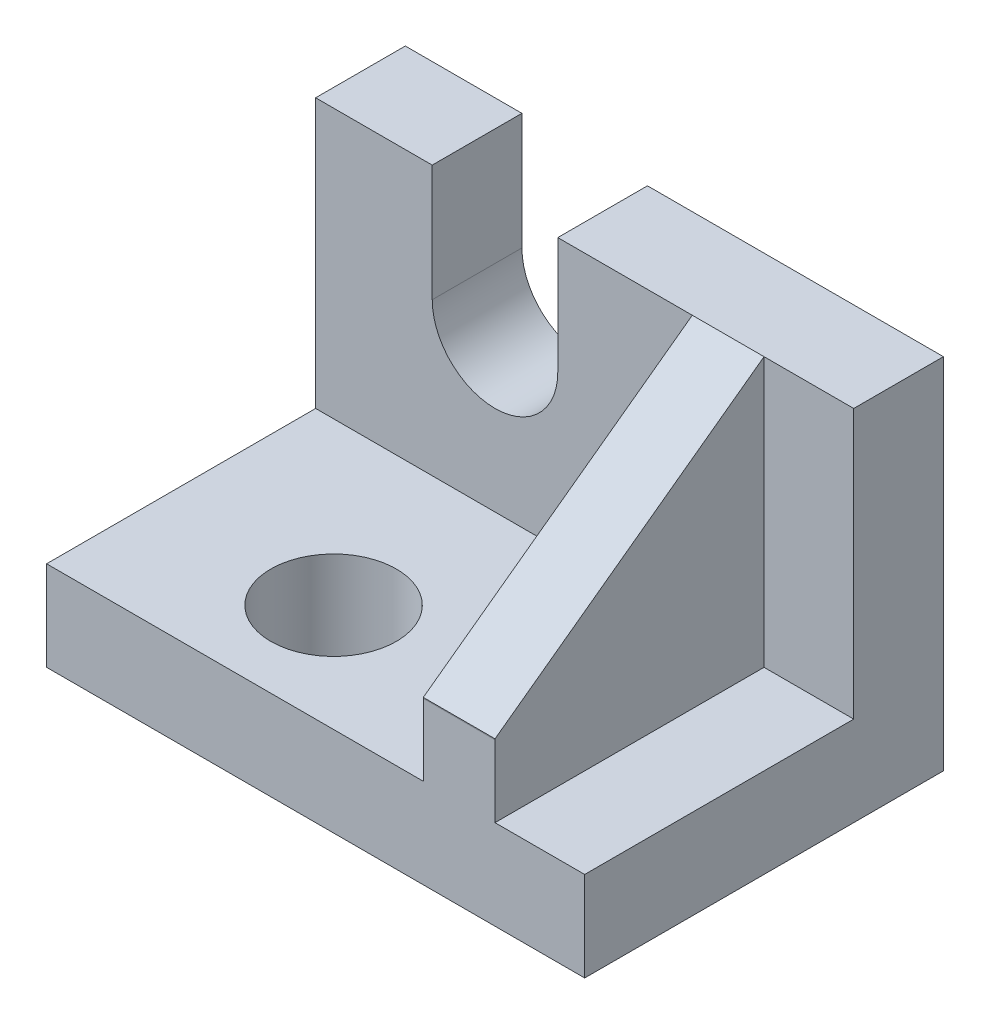
from build123d import *

# Parameters (mm, degrees)
SKETCH_3_W               = 60
SKETCH_3_H               = 40
EXTRUDE_2_DEPTH          = 40
CUT_EXTRUDE_1_DEPTH      = 39
CUT_EXTRUDE_1_DEPTH_BACK = 0.0001
SKETCH_5_W               = 10
SKETCH_5_H               = 30
CUT_EXTRUDE_2_DEPTH      = 43
SKETCH_6_W               = 14
SKETCH_6_H               = 13
CUT_EXTRUDE_3_DEPTH      = 34
SKETCH_7_W               = 14
SKETCH_7_H               = 13
CUT_EXTRUDE_4_DEPTH      = 34
CUT_EXTRUDE_5_DEPTH      = 34
CUT_EXTRUDE_7_DEPTH      = 34
SKETCH_11_R              = 7
CUT_EXTRUDE_8_DEPTH      = 37


with BuildPart() as part:
    # 草图3 → 凸台-拉伸2 (new body)
    with BuildSketch(Plane(origin=(0, 0, 0), x_dir=(1, 0, 0), z_dir=(0, 1, 0))):
        with Locations((-30, -20)):
            Rectangle(SKETCH_3_W, SKETCH_3_H)
    extrude(amount=EXTRUDE_2_DEPTH)

    # 草图4 → 切除-拉伸1 (cut, two sides)
    with BuildSketch(Plane.XY.offset(10)) as cut_extrude_1_sk:
        Polygon((-60, 40), (-47, 40), (-47, 27), (-33, 27), (-33, 40), (-18, 40), (-18, 10), (-60, 10), align=None)
    extrude(amount=CUT_EXTRUDE_1_DEPTH, mode=Mode.SUBTRACT)
    extrude(cut_extrude_1_sk.sketch, amount=-CUT_EXTRUDE_1_DEPTH_BACK, mode=Mode.SUBTRACT)

    # 草图5 → 切除-拉伸2 (cut)
    with BuildSketch(Plane.XY.offset(10)):
        with Locations((-5, 25)):
            Rectangle(SKETCH_5_W, SKETCH_5_H)
    extrude(amount=CUT_EXTRUDE_2_DEPTH, mode=Mode.SUBTRACT)

    # 草图6 → 切除-拉伸3 (cut)
    with BuildSketch(Plane.XY.offset(10)):
        with Locations((-40, 33.5)):
            Rectangle(SKETCH_6_W, SKETCH_6_H)
    extrude(amount=CUT_EXTRUDE_3_DEPTH, mode=Mode.SUBTRACT)

    # 草图7 → 切除-拉伸4 (cut)
    with BuildSketch(Plane.XY.offset(10)):
        with Locations((-40, 33.5)):
            Rectangle(SKETCH_7_W, SKETCH_7_H)
    extrude(amount=-CUT_EXTRUDE_4_DEPTH, mode=Mode.SUBTRACT)

    # 草图8 → 切除-拉伸5 (cut)
    with BuildSketch(Plane.XY.offset(10)):
        with BuildLine():
            Line((-47, 27), (-33, 27))
            ThreePointArc((-33, 27), (-40, 20), (-47, 27))
        make_face()
    extrude(amount=-CUT_EXTRUDE_5_DEPTH, mode=Mode.SUBTRACT)

    # 草图10 → 切除-拉伸7 (cut)
    with BuildSketch(Plane(origin=(0, 0, 0), x_dir=(0, 0, -1), z_dir=(1, 0, 0))):
        Polygon((-40, 40), (-40, 18), (-39.997988347, 18.098350801), (-10, 40), align=None)
    extrude(amount=-CUT_EXTRUDE_7_DEPTH, mode=Mode.SUBTRACT)

    # 草图11 → 切除-拉伸8 (cut)
    with BuildSketch(Plane(origin=(0, 0, 0), x_dir=(1, 0, 0), z_dir=(0, 1, 0))):
        with Locations((-40, -28)):
            Circle(SKETCH_11_R)
    extrude(amount=CUT_EXTRUDE_8_DEPTH, mode=Mode.SUBTRACT)


solid = part.part
